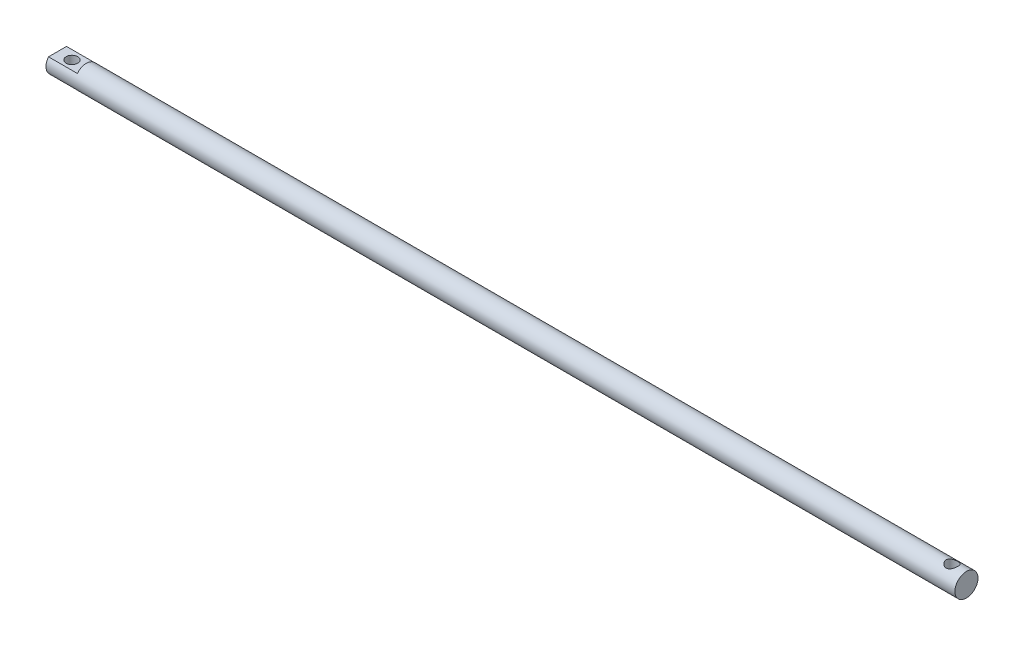
from build123d import *

# Parameters (mm, degrees)
SKETCH_1_R               = 8
EXTRUDE_1_DEPTH          = 630
SKETCH_2_R               = 4
CUT_EXTRUDE_1_DEPTH      = 9
CUT_EXTRUDE_1_DEPTH_BACK = 9
SKETCH_3_OUTSIDE_W       = 144.082
SKETCH_3_OUTSIDE_H       = 144.082
SKETCH_3_OUTSIDE_W_2     = 20
SKETCH_3_OUTSIDE_H_2     = 10
CUT_EXTRUDE_2_DEPTH      = 20


with BuildPart() as part:
    # 草图1 → 凸台-拉伸1 (new body)
    with BuildSketch(Plane(origin=(0, 0, 0), x_dir=(0, 0, -1), z_dir=(1, 0, 0))):
        Circle(SKETCH_1_R)
    extrude(amount=EXTRUDE_1_DEPTH)

    # 草图2 → 切除-拉伸1 (cut, two sides)
    with BuildSketch(Plane(origin=(0, 0, 0), x_dir=(1, 0, 0), z_dir=(0, 1, 0))) as cut_extrude_1_sk:
        with Locations((10, 0)):
            Circle(SKETCH_2_R)
        with Locations((620, 0)):
            Circle(SKETCH_2_R)
    extrude(amount=CUT_EXTRUDE_1_DEPTH, mode=Mode.SUBTRACT)
    extrude(cut_extrude_1_sk.sketch, amount=-CUT_EXTRUDE_1_DEPTH_BACK, mode=Mode.SUBTRACT)

    # 草图3 outside → 切除-拉伸2 (cut)
    with BuildSketch(Plane.ZY):
        Rectangle(SKETCH_3_OUTSIDE_W, SKETCH_3_OUTSIDE_H)
        Rectangle(SKETCH_3_OUTSIDE_W_2, SKETCH_3_OUTSIDE_H_2, mode=Mode.SUBTRACT)
    extrude(amount=-CUT_EXTRUDE_2_DEPTH, mode=Mode.SUBTRACT)


solid = part.part
